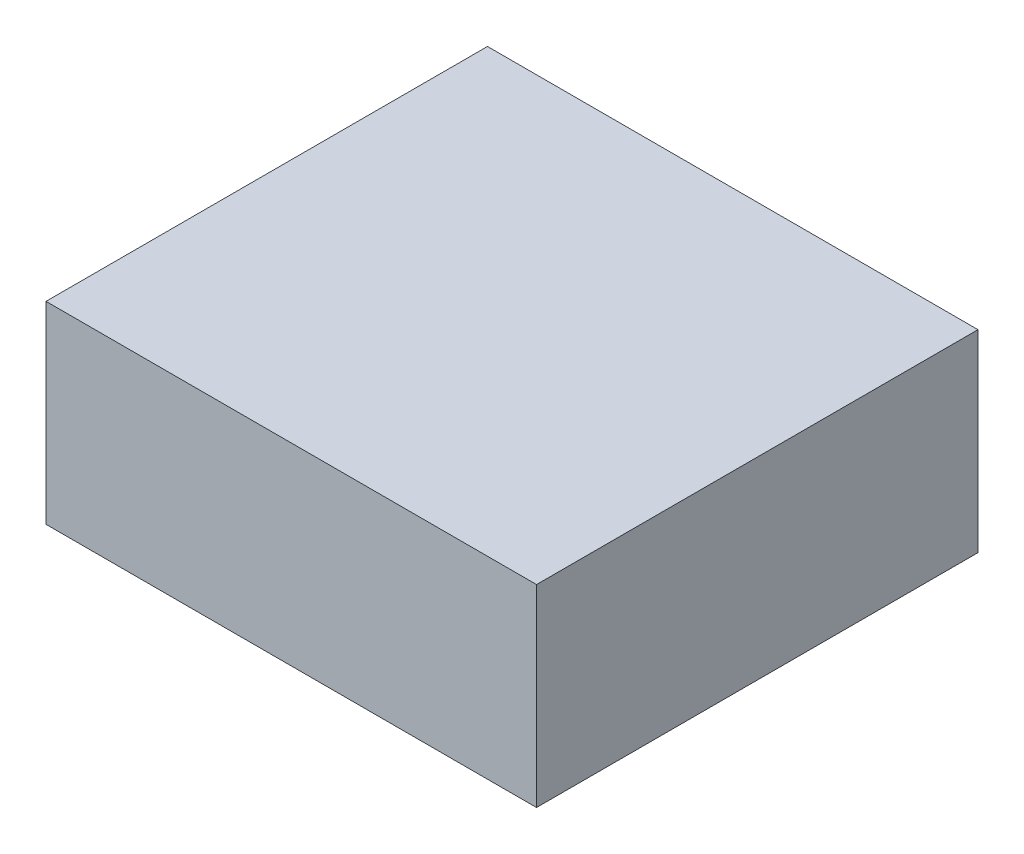
from build123d import *

# Parameters (mm, degrees)
SKETCH1_W           = 25.4
SKETCH1_H           = 22.86
BOSS_EXTRUDE1_DEPTH = 10


with BuildPart() as part:
    # Sketch1 → Boss-Extrude1 (new body)
    with BuildSketch(Plane(origin=(0, 0, 0), x_dir=(1, 0, 0), z_dir=(0, 1, 0))):
        Rectangle(SKETCH1_W, SKETCH1_H)
    extrude(amount=BOSS_EXTRUDE1_DEPTH)


solid = part.part
